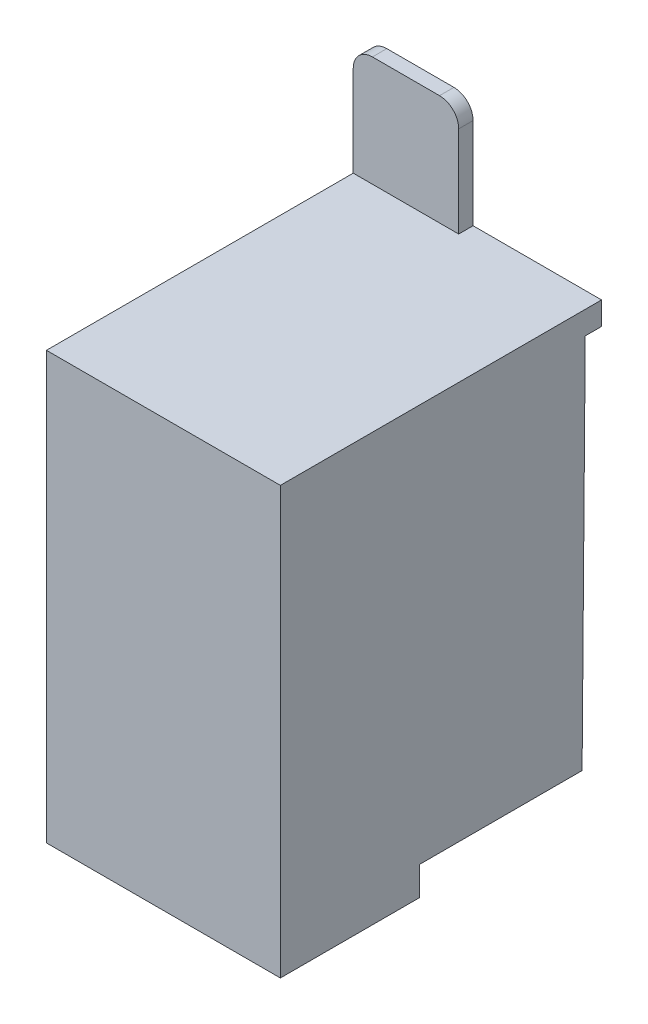
from build123d import *

# Parameters (mm, degrees)
SKETCH1_W           = 24.4
SKETCH1_H           = 33.5
BOSS_EXTRUDE1_DEPTH = 41.5
BOSS_EXTRUDE2_DEPTH = 3
SKETCH4_W           = 11
SKETCH4_H           = 1.5
BOSS_EXTRUDE3_DEPTH = 11.5
CUT_EXTRUDE1_DEPTH  = 25.4
FILLET1_R           = 2


with BuildPart() as part:
    # Sketch1 → Boss-Extrude1 (new body)
    with BuildSketch(Plane(origin=(0, 0, 0), x_dir=(1, 0, 0), z_dir=(0, 1, 0))):
        with Locations((12.2, 16.75)):
            Rectangle(SKETCH1_W, SKETCH1_H)
    extrude(amount=BOSS_EXTRUDE1_DEPTH)

    # Sketch3 → Boss-Extrude2 (add)
    with BuildSketch(Plane.XZ):
        Polygon((0, 0), (24.4, 0), (24.4, -14.5), (17.95, -14.5), (17.95, -27.5), (6.45, -27.5), (6.45, -14.5), (0, -14.5), align=None)
    extrude(amount=BOSS_EXTRUDE2_DEPTH)

    # Sketch4 → Boss-Extrude3 (add)
    with BuildSketch(Plane(origin=(0, 41.5, 0), x_dir=(-1, 0, 0), z_dir=(0, 1, 0))):
        with Locations((-5.5, -32.75)):
            Rectangle(SKETCH4_W, SKETCH4_H)
    extrude(amount=BOSS_EXTRUDE3_DEPTH)

    # Sketch5 → Cut-Extrude1 (cut, through all)
    with BuildSketch(Plane(origin=(24.4, 0, 0), x_dir=(0, 0, -1), z_dir=(1, 0, 0))):
        Polygon((33.5, 0), (31.46940795, 0), (31.797940048, 39.10064674), (33.5, 39.10064674), align=None)
    extrude(amount=-CUT_EXTRUDE1_DEPTH, mode=Mode.SUBTRACT)

    # Fillet1
    fillet1_edges = [part.edges().sort_by_distance(p)[0] for p in [
        (0, 53, -32.75),
        (11, 53, -32.75),
    ]]
    fillet(fillet1_edges, radius=FILLET1_R)


solid = part.part
